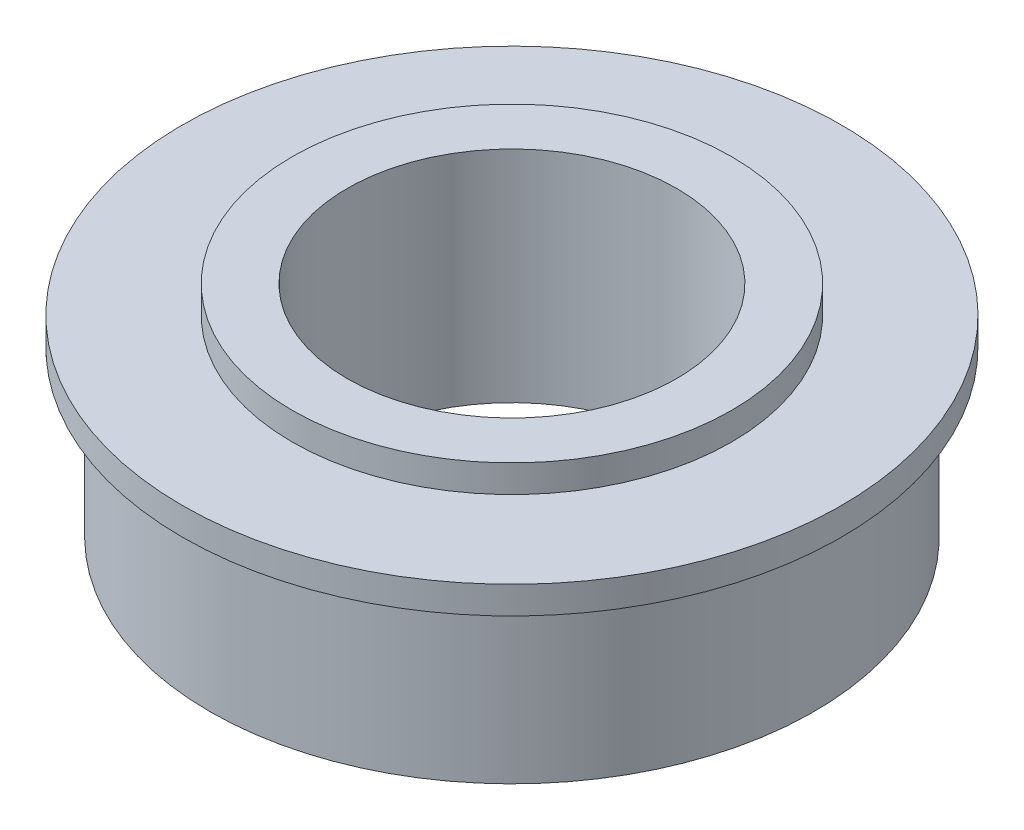
from build123d import *


with BuildPart() as part:
    # Sketch1 → Revolve1 (revolve)
    with BuildSketch(Plane.XY):
        Polygon((9.525, 1.5875), (12.7, 1.5875), (12.7, 0), (19.05, 0), (19.05, -1.5875), (17.4625, -1.5875), (17.4625, -11.1125), (9.525, -11.1125), align=None)
    revolve(axis=Axis((0, 0, 0), (0, -1, 0)))


solid = part.part
